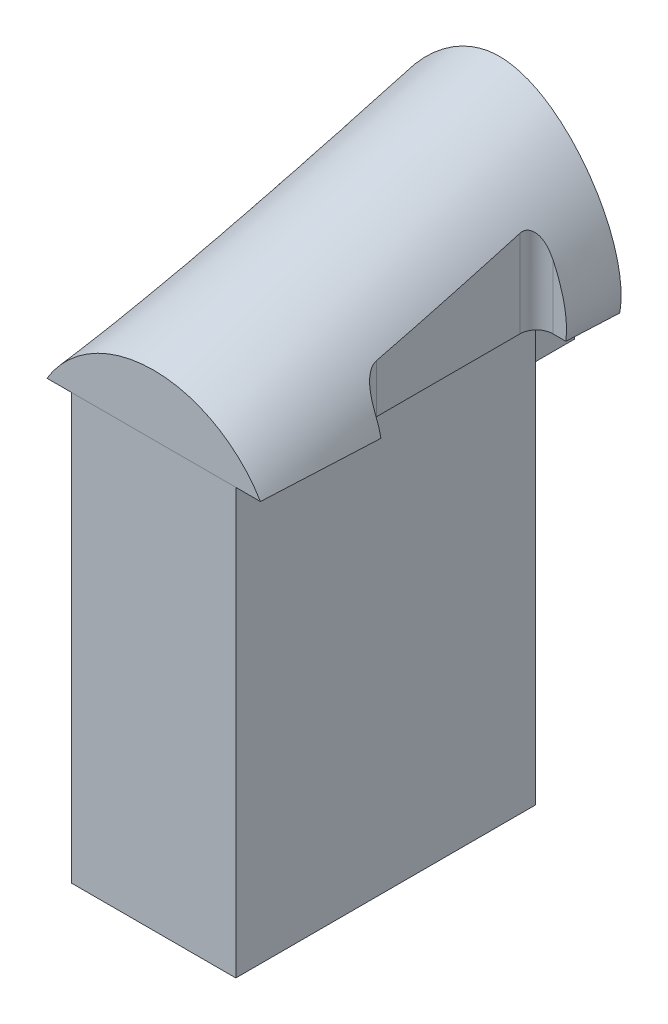
from build123d import *

# Parameters (mm, degrees)
SKETCH_1_W          = 40
SKETCH_1_H          = 73
EXTRUDE_1_DEPTH     = 51.75
SKETCH_2_W          = 26.5
SKETCH_2_H          = 11
EXTRUDE_2_DEPTH     = 10.5
CUT_EXTRUDE_1_DEPTH = 118.658825115


with BuildPart() as part:
    # 草图1 → 凸台-拉伸1 (new, symmetric)
    with BuildSketch(Plane(origin=(0, 0, 0), x_dir=(1, 0, 0), z_dir=(0, 1, 0))):
        Rectangle(SKETCH_1_W, SKETCH_1_H)
    extrude(amount=EXTRUDE_1_DEPTH, both=True)

    # 草图2 → 凸台-拉伸2 (add)
    with BuildSketch(Plane(origin=(0, 0, -36.5), x_dir=(-1, 0, 0), z_dir=(0, 0, -1))):
        with Locations((-5.75, 46.25)):
            Rectangle(SKETCH_2_W, SKETCH_2_H)
    extrude(amount=EXTRUDE_2_DEPTH)


with BuildPart() as body_2:
    # 草图3 → 放样1 section 0
    with BuildSketch(Plane(origin=(0, 0, -47), x_dir=(-1, 0, 0), z_dir=(0, 0, -1))):
        with BuildLine():
            Line((-30, 51.75), (30, 51.75))
            add(Edge.make_bspline(
                [(-30, 51.75), (-32.960840364, 67.552970125), (-0.122307099, 116.257852524), (33.072086404, 64.936710937), (30, 51.75)],
                knots=[0, 0, 0, 0, 0.500504929, 1, 1, 1, 1], degree=3))
        make_face()
    # 草图4 for 放样1 → 放样1 section 1
    with BuildSketch(Plane.XY.offset(36.5)):
        with BuildLine():
            Line((-26, 51.75), (26, 51.75))
            # circular arc as an exact rational Bezier (weights 1, cos(half-angle), 1)
            Bezier((26, 51.75), (0, 95.0040341), (-26, 51.75), weights=[1, 0.515188813, 1])
        make_face()
    loft()

    # 草图5 → 切除-拉伸1 (cut, through all)
    with BuildSketch(Plane.XZ.offset(-51.75)):
        with BuildLine():
            Line((-27.341317365, 8.5), (-26.243023445, 8.5))
            ThreePointArc((-26.243023445, 8.5), (-23.41459632, 7.328427125), (-22.243023445, 4.5))
            Line((-22.243023445, 4.5), (-22.243023445, -30.5))
            ThreePointArc((-22.243023445, -30.5), (-23.41459632, -33.328427125), (-26.243023445, -34.5))
            Line((-26.243023445, -34.5), (-29.401197605, -34.5))
            Line((-29.401197605, -34.5), (-36.989276173, -34.5))
            Line((-36.989276173, -34.5), (-36.989276173, 9.347472548))
            Line((-36.989276173, 9.347472548), (-27.341317365, 8.5))
        make_face()
        with BuildLine():
            Line((36.989276173, 9.347472548), (27.341317365, 8.5))
            Line((27.341317365, 8.5), (26.243023445, 8.5))
            ThreePointArc((26.243023445, 8.5), (23.41459632, 7.328427125), (22.243023445, 4.5))
            Line((22.243023445, 4.5), (22.243023445, -30.5))
            ThreePointArc((22.243023445, -30.5), (23.41459632, -33.328427125), (26.243023445, -34.5))
            Line((26.243023445, -34.5), (29.401197605, -34.5))
            Line((29.401197605, -34.5), (36.989276173, -34.5))
            Line((36.989276173, -34.5), (36.989276173, 9.347472548))
        make_face()
    extrude(amount=-CUT_EXTRUDE_1_DEPTH, mode=Mode.SUBTRACT)


solid = Compound([part.part, body_2.part])
